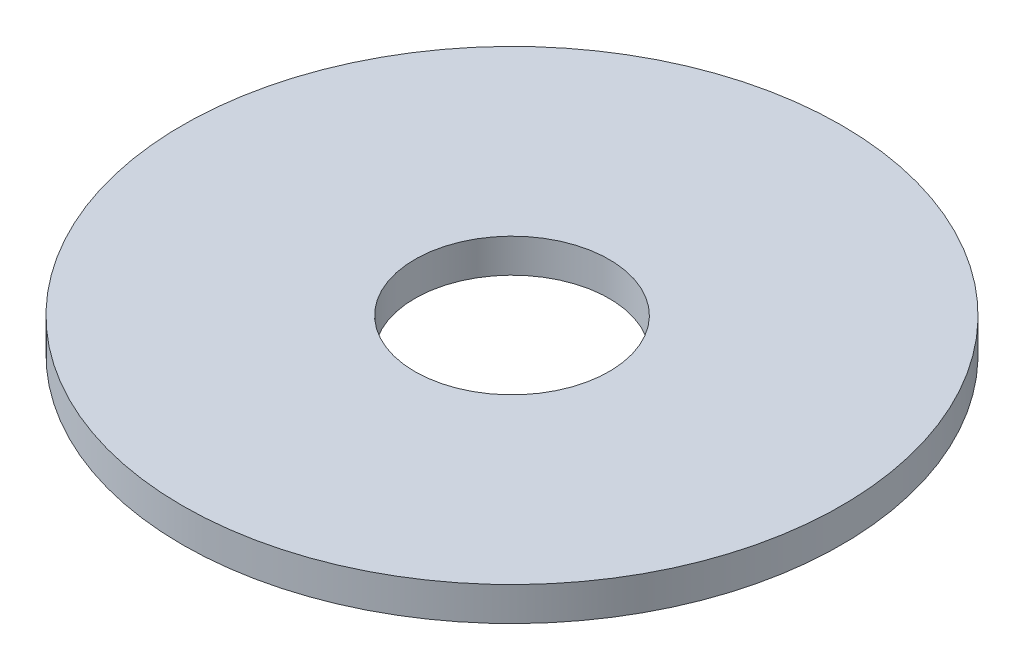
from build123d import *

# Parameters (mm, degrees)
SKETCH1_R           = 19.5
SKETCH1_R_2         = 5.75
BOSS_EXTRUDE1_DEPTH = 2


with BuildPart() as part:
    # Sketch1 → Boss-Extrude1 (new body)
    with BuildSketch(Plane(origin=(0, 0, 0), x_dir=(1, 0, 0), z_dir=(0, 1, 0))):
        Circle(SKETCH1_R)
        Circle(SKETCH1_R_2, mode=Mode.SUBTRACT)
    extrude(amount=BOSS_EXTRUDE1_DEPTH)


solid = part.part
